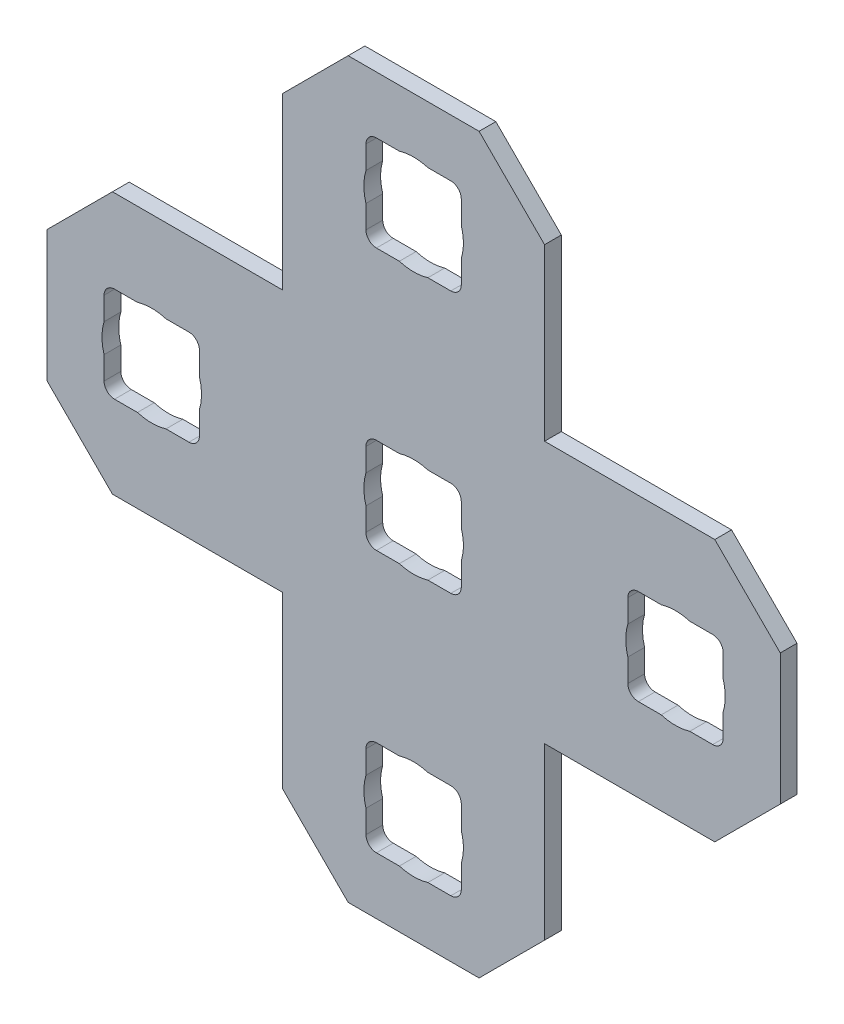
from build123d import *

# Parameters (mm, degrees)
BOSS_EXTRUDE1_DEPTH = 0.8128
SKETCH2_R           = 2.413
CUT_EXTRUDE1_DEPTH  = 2.54


with BuildPart() as part:
    # Sketch1 → Boss-Extrude1 (new body)
    with BuildSketch(Plane(origin=(0, 0, 0), x_dir=(-1, 0, 0), z_dir=(0, 0, -1))):
        Polygon((8.385680008, -18.845494556), (5.210680008, -15.670494556), (-3.044319992, -15.670494556), (-3.044319992, -7.415494556), (-6.219319992, -4.240494556), (-12.569319992, -4.240494556), (-15.744319992, -7.415494556), (-15.744319992, -15.670494556), (-23.999319992, -15.670494556), (-27.174319992, -18.845494556), (-27.174319992, -25.195494556), (-23.999319992, -28.370494556), (-15.744319992, -28.370494556), (-15.744319992, -36.625494556), (-12.569319992, -39.800494556), (-6.219319992, -39.800494556), (-3.044319992, -36.625494556), (-3.044319992, -28.370494556), (5.210680008, -28.370494556), (8.385680008, -25.195494556), align=None)
        with BuildLine():
            Line((5.109080019, -24.331894556), (1.502279997, -24.331894556))
            ThreePointArc((1.502279997, -24.331894556), (1.14306976, -24.183104805), (0.994280008, -23.823894568))
            Line((0.994280008, -23.823894568), (0.994280008, -20.217094545))
            ThreePointArc((0.994280008, -20.217094545), (1.14306976, -19.857884308), (1.502279997, -19.709094556))
            Line((1.502279997, -19.709094556), (5.109080019, -19.709094556))
            ThreePointArc((5.109080019, -19.709094556), (5.468290256, -19.857884308), (5.617080008, -20.217094545))
            Line((5.617080008, -20.217094545), (5.617080008, -23.823894568))
            ThreePointArc((5.617080008, -23.823894568), (5.468290256, -24.183104805), (5.109080019, -24.331894556))
        make_face(mode=Mode.SUBTRACT)
        with BuildLine():
            Line((-7.590919981, -24.331894556), (-11.197720003, -24.331894556))
            ThreePointArc((-11.197720003, -24.331894556), (-11.55693024, -24.183104805), (-11.705719992, -23.823894568))
            Line((-11.705719992, -23.823894568), (-11.705719992, -20.217094545))
            ThreePointArc((-11.705719992, -20.217094545), (-11.55693024, -19.857884308), (-11.197720003, -19.709094556))
            Line((-11.197720003, -19.709094556), (-7.590919981, -19.709094556))
            ThreePointArc((-7.590919981, -19.709094556), (-7.231709744, -19.857884308), (-7.082919992, -20.217094545))
            Line((-7.082919992, -20.217094545), (-7.082919992, -23.823894568))
            ThreePointArc((-7.082919992, -23.823894568), (-7.231709744, -24.183104805), (-7.590919981, -24.331894556))
        make_face(mode=Mode.SUBTRACT)
        with BuildLine():
            Line((-11.197720003, -7.009094556), (-7.590919981, -7.009094556))
            ThreePointArc((-7.590919981, -7.009094556), (-7.231709744, -7.157884308), (-7.082919992, -7.517094545))
            Line((-7.082919992, -7.517094545), (-7.082919992, -11.123894568))
            ThreePointArc((-7.082919992, -11.123894568), (-7.231709744, -11.483104805), (-7.590919981, -11.631894556))
            Line((-7.590919981, -11.631894556), (-11.197720003, -11.631894556))
            ThreePointArc((-11.197720003, -11.631894556), (-11.55693024, -11.483104805), (-11.705719992, -11.123894568))
            Line((-11.705719992, -11.123894568), (-11.705719992, -7.517094545))
            ThreePointArc((-11.705719992, -7.517094545), (-11.55693024, -7.157884308), (-11.197720003, -7.009094556))
        make_face(mode=Mode.SUBTRACT)
        with BuildLine():
            Line((-20.290919981, -24.331894556), (-23.897720003, -24.331894556))
            ThreePointArc((-23.897720003, -24.331894556), (-24.25693024, -24.183104805), (-24.405719992, -23.823894568))
            Line((-24.405719992, -23.823894568), (-24.405719992, -20.217094545))
            ThreePointArc((-24.405719992, -20.217094545), (-24.25693024, -19.857884308), (-23.897720003, -19.709094556))
            Line((-23.897720003, -19.709094556), (-20.290919981, -19.709094556))
            ThreePointArc((-20.290919981, -19.709094556), (-19.931709744, -19.857884308), (-19.782919992, -20.217094545))
            Line((-19.782919992, -20.217094545), (-19.782919992, -23.823894568))
            ThreePointArc((-19.782919992, -23.823894568), (-19.931709744, -24.183104805), (-20.290919981, -24.331894556))
        make_face(mode=Mode.SUBTRACT)
        with BuildLine():
            Line((-11.705719992, -36.523894568), (-11.705719992, -32.917094545))
            ThreePointArc((-11.705719992, -32.917094545), (-11.55693024, -32.557884308), (-11.197720003, -32.409094556))
            Line((-11.197720003, -32.409094556), (-7.590919981, -32.409094556))
            ThreePointArc((-7.590919981, -32.409094556), (-7.231709744, -32.557884308), (-7.082919992, -32.917094545))
            Line((-7.082919992, -32.917094545), (-7.082919992, -36.523894568))
            ThreePointArc((-7.082919992, -36.523894568), (-7.231709744, -36.883104805), (-7.590919981, -37.031894556))
            Line((-7.590919981, -37.031894556), (-11.197720003, -37.031894556))
            ThreePointArc((-11.197720003, -37.031894556), (-11.55693024, -36.883104805), (-11.705719992, -36.523894568))
        make_face(mode=Mode.SUBTRACT)
    extrude(amount=-BOSS_EXTRUDE1_DEPTH)

    # Sketch2 → Cut-Extrude1 (cut)
    with BuildSketch(Plane.XY.offset(0.8128)):
        with Locations((-3.305680008, -22.020494556)):
            Circle(SKETCH2_R)
        with Locations((9.394319992, -22.020494556)):
            Circle(SKETCH2_R)
        with Locations((9.394319992, -9.320494556)):
            Circle(SKETCH2_R)
        with Locations((22.094319992, -22.020494556)):
            Circle(SKETCH2_R)
        with Locations((9.394319992, -34.720494556)):
            Circle(SKETCH2_R)
    extrude(amount=-CUT_EXTRUDE1_DEPTH, mode=Mode.SUBTRACT)


solid = part.part
